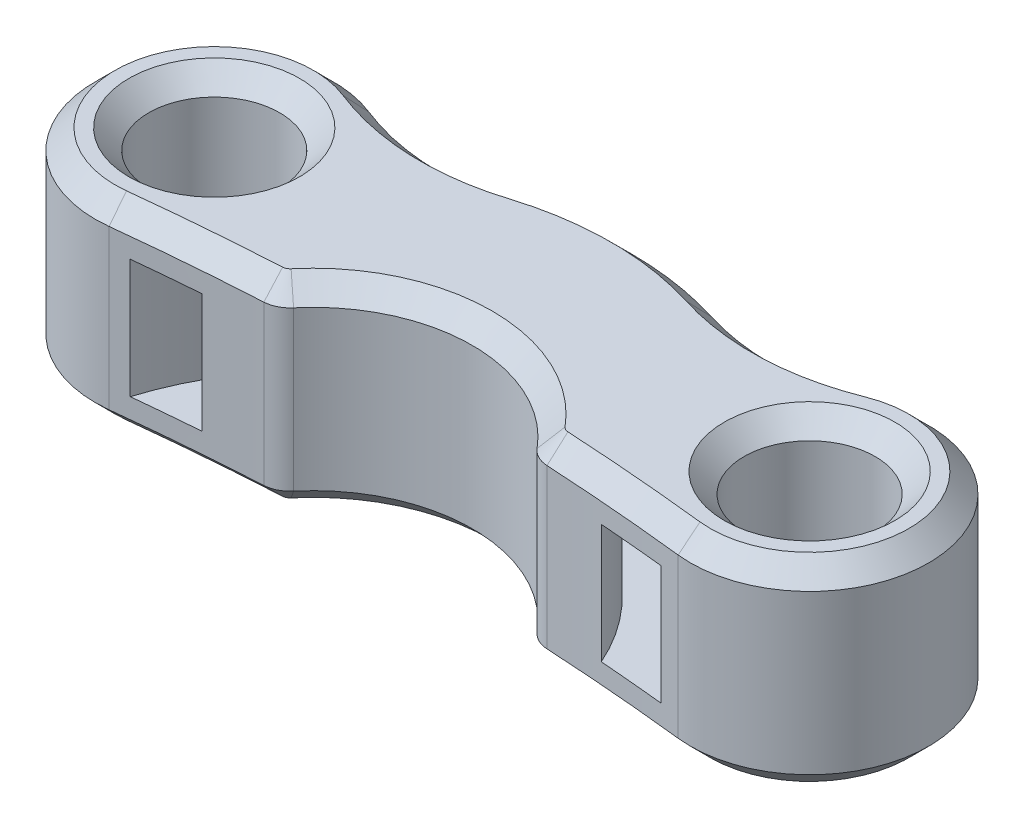
from build123d import *

# Parameters (mm, degrees)
SKETCH1_R           = 1.65
BOSS_EXTRUDE1_DEPTH = 5
SKETCH2_W           = 1.5
SKETCH2_H           = 3
FILLET1_R           = 0.7
CHAMFER1_SIZE       = 0.5


with BuildPart() as part:
    # Sketch1 → Boss-Extrude1 (new body)
    with BuildSketch(Plane(origin=(0, 0, 0), x_dir=(1, 0, 0), z_dir=(0, 1, 0))):
        with BuildLine():
            ThreePointArc((-6.391530464, 2.787704304), (-10.473118103, 0.400710302), (-7.169117647, -2.981696978))
            ThreePointArc((-7.169117647, -2.981696978), (-5.211302896, -2.794373502), (-3.248717022, -2.666368129))
            ThreePointArc((-3.248717022, -2.666368129), (0, -1), (3.248717022, -2.666368129))
            ThreePointArc((3.248717022, -2.666368129), (5.211302896, -2.794373502), (7.169117647, -2.981696978))
            ThreePointArc((7.169117647, -2.981696978), (10.473118103, 0.400710302), (6.391530464, 2.787704304))
            ThreePointArc((6.391530464, 2.787704304), (4.401545037, 2.367406779), (2.385480795, 2.636064521))
            ThreePointArc((2.385480795, 2.636064521), (0, 3), (-2.385480795, 2.636064521))
            ThreePointArc((-2.385480795, 2.636064521), (-4.401545037, 2.367406779), (-6.391530464, 2.787704304))
        make_face()
        with Locations((-7.5, 0)):
            Circle(SKETCH1_R, mode=Mode.SUBTRACT)
        with Locations((7.5, 0)):
            Circle(SKETCH1_R, mode=Mode.SUBTRACT)
    extrude(amount=BOSS_EXTRUDE1_DEPTH)

    # Sketch2 → Cut-Revolve1 (revolve, cut)
    with BuildSketch(Plane(origin=(0, 0, 0), x_dir=(0, 0, -1), z_dir=(1, 0, 0))):
        with Locations((1.25, 2.5)):
            Rectangle(SKETCH2_W, SKETCH2_H)
    revolve(axis=Axis((0, 0, 5), (0, 1, 0)), mode=Mode.SUBTRACT)

    # Fillet1
    fillet1_edges = [part.edges().sort_by_distance(p)[0] for p in [
        (3.248717022, 2.5, 2.666368129),
        (-3.248717022, 2.5, 2.666368129),
    ]]
    fillet(fillet1_edges, radius=FILLET1_R)

    # Chamfer1
    chamfer1_edges = [part.edges().sort_by_distance(p)[0] for p in [
        (-4.401545037, 0, -2.367406779),
        (0, 0, -3),
        (-9.15, 5, 0),
        (4.401545037, 0, -2.367406779),
        (10.473118103, 0, -0.400710302),
        (-5.369814622, 0, 2.80731824),
        (-10.473118103, 0, -0.400710302),
        (-9.15, 0, 0),
        (5.85, 0, 0),
        (-10.473118103, 5, -0.400710302),
        (-5.369814622, 5, 2.80731824),
        (10.473118103, 5, -0.400710302),
        (4.401545037, 5, -2.367406779),
        (5.369814622, 0, 2.80731824),
        (0, 5, -3),
        (5.369814622, 5, 2.80731824),
        (0, 0, 1),
        (-3.29118131, 0, 2.609929037),
        (3.29118131, 0, 2.609929037),
        (0, 5, 1),
        (-4.401545037, 5, -2.367406779),
        (-3.29118131, 5, 2.609929037),
        (3.29118131, 5, 2.609929037),
        (5.85, 5, 0),
    ]]
    chamfer(chamfer1_edges, length=CHAMFER1_SIZE)


solid = part.part
